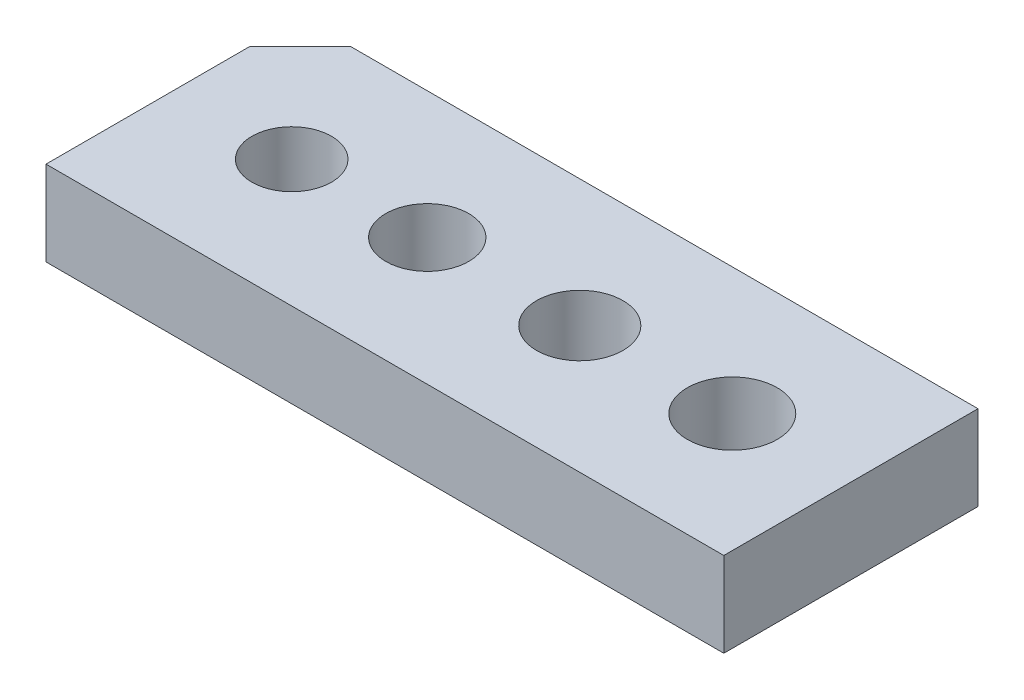
from build123d import *

# Parameters (mm, degrees)
SKETCH1_R           = 2.35
SKETCH1_R_2         = 2.55
SKETCH1_R_3         = 2.65
SKETCH1_R_4         = 2.45
BOSS_EXTRUDE1_DEPTH = 5


with BuildPart() as part:
    # Sketch1 → Boss-Extrude1 (new body)
    with BuildSketch(Plane(origin=(0, 0, 0), x_dir=(1, 0, 0), z_dir=(0, 1, 0))):
        Polygon((-17, 7.5), (20, 7.5), (20, -7.5), (-20, -7.5), (-20, 4.5), align=None)
        with Locations((-13, 0)):
            Circle(SKETCH1_R, mode=Mode.SUBTRACT)
        with Locations((4, 0)):
            Circle(SKETCH1_R_2, mode=Mode.SUBTRACT)
        with Locations((13, 0)):
            Circle(SKETCH1_R_3, mode=Mode.SUBTRACT)
        with Locations((-5, 0)):
            Circle(SKETCH1_R_4, mode=Mode.SUBTRACT)
    extrude(amount=BOSS_EXTRUDE1_DEPTH)


solid = part.part
